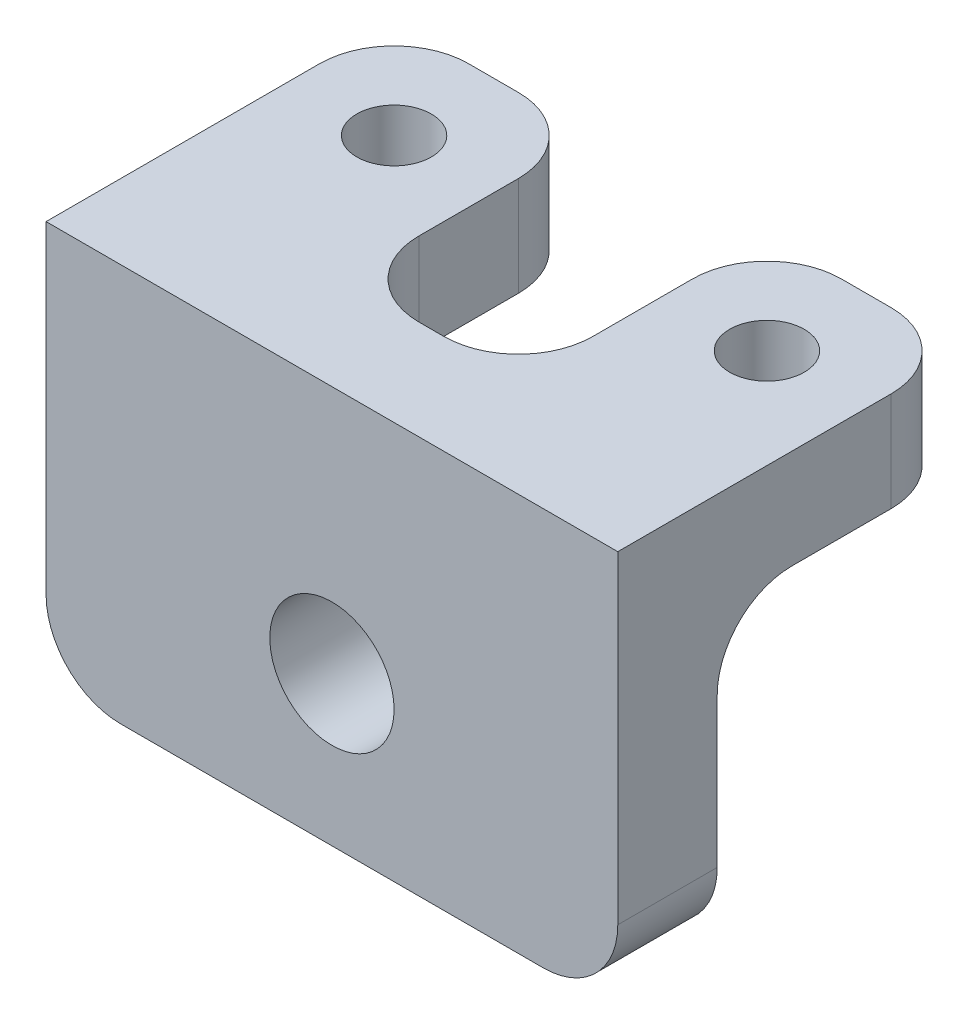
from build123d import *

# Parameters (mm, degrees)
ESBO_O1_R                = 1.5
RESSALTO_EXTRUS_O1_DEPTH = 4
ESBO_O2_W                = 23
ESBO_O2_H                = 12
ESBO_O2_R                = 2.5
RESSALTO_EXTRUS_O2_DEPTH = 4
FILETE1_R                = 3


with BuildPart() as part:
    # Esboço1 → Ressalto-extrusão1 (new body)
    with BuildSketch(Plane(origin=(0, 0, 0), x_dir=(1, 0, 0), z_dir=(0, 1, 0))):
        Polygon((-3.5, 0), (3.5, 0), (3.5, 10), (11.5, 10), (11.5, -4), (-11.5, -4), (-11.5, 10), (-3.5, 10), align=None)
        with Locations((-7.5, 6)):
            Circle(ESBO_O1_R, mode=Mode.SUBTRACT)
        with Locations((7.5, 6)):
            Circle(ESBO_O1_R, mode=Mode.SUBTRACT)
    extrude(amount=RESSALTO_EXTRUS_O1_DEPTH)

    # Esboço2 → Ressalto-extrusão2 (add)
    with BuildSketch(Plane.XY.offset(4)):
        with Locations((0, -6)):
            Rectangle(ESBO_O2_W, ESBO_O2_H)
        with Locations((0, -6)):
            Circle(ESBO_O2_R, mode=Mode.SUBTRACT)
    extrude(amount=-RESSALTO_EXTRUS_O2_DEPTH)

    # Filete1
    filete1_edges = [part.edges().sort_by_distance(p)[0] for p in [
        (-3.5, 2, 0),
        (3.5, 2, 0),
        (3.5, 2, -10),
        (11.5, 2, -10),
        (-11.5, 2, -10),
        (-3.5, 2, -10),
        (-7.5, 0, 0),
        (11.5, -12, 2),
        (-11.5, -12, 2),
        (7.5, 0, 0),
    ]]
    fillet(filete1_edges, radius=FILETE1_R)


solid = part.part
